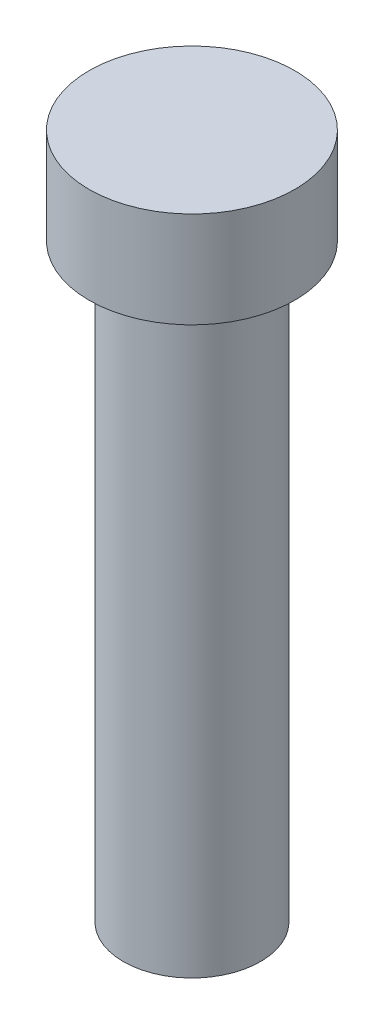
from build123d import *

# Parameters (mm, degrees)
SKETCH1_R           = 5
BOSS_EXTRUDE1_DEPTH = 43
SKETCH2_R           = 7.5
BOSS_EXTRUDE2_DEPTH = 7


with BuildPart() as part:
    # Sketch1 → Boss-Extrude1 (new body)
    with BuildSketch(Plane(origin=(0, 0, 0), x_dir=(1, 0, 0), z_dir=(0, 1, 0))):
        Circle(SKETCH1_R)
    extrude(amount=BOSS_EXTRUDE1_DEPTH)

    # Sketch2 → Boss-Extrude2 (add)
    with BuildSketch(Plane(origin=(0, 43, 0), x_dir=(1, 0, 0), z_dir=(0, 1, 0))):
        Circle(SKETCH2_R)
    extrude(amount=BOSS_EXTRUDE2_DEPTH)


solid = part.part
